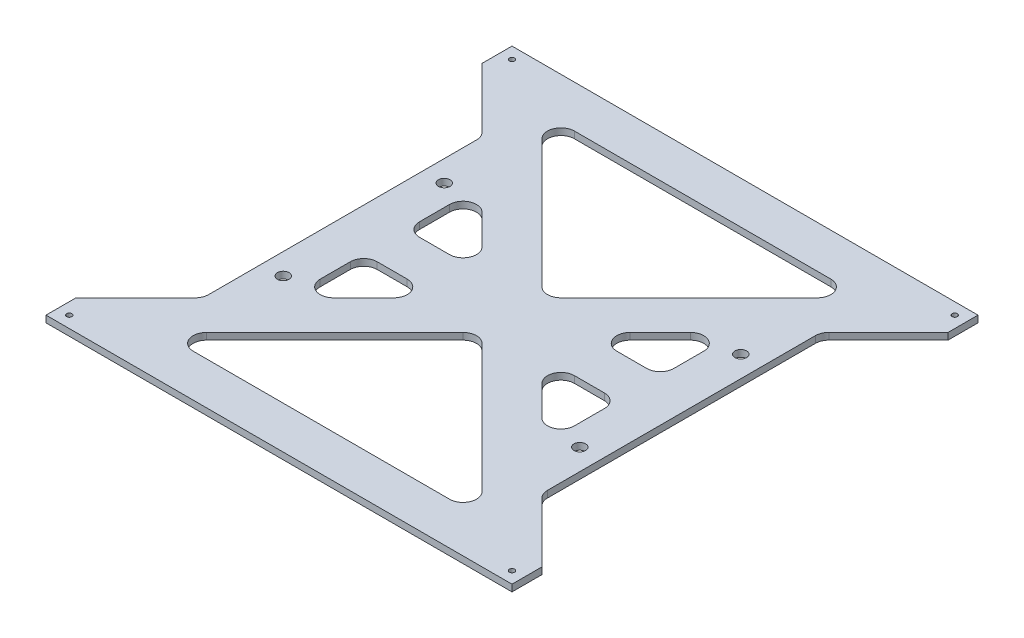
from build123d import *

# Parameters (mm, degrees)
SKETCH1_W             = 220
SKETCH1_H             = 220
BOSS_EXTRUDE1_DEPTH   = 3.175
M3X0_5_TAPPED_HOLE1_D = 2.5
SKETCH4_R             = 2.75
CUT_EXTRUDE1_DEPTH    = 4.175
CUT_EXTRUDE2_DEPTH    = 4.175


with BuildPart() as part:
    # Sketch1 → Boss-Extrude1 (new body)
    with BuildSketch(Plane(origin=(0, 0, 0), x_dir=(1, 0, 0), z_dir=(0, 1, 0))):
        Rectangle(SKETCH1_W, SKETCH1_H)
    extrude(amount=BOSS_EXTRUDE1_DEPTH)

    # M3x0.5 Tapped Hole1 (through all)
    with Locations(Plane(origin=(0, 3.175, 0), x_dir=(-1, 0, 0), z_dir=(0, 1, 0))):
        with Locations((104.5, -104.5), (-104.5, -104.5), (-104.5, 104.5), (104.5, 104.5)):
            Hole(M3X0_5_TAPPED_HOLE1_D / 2)

    # Sketch4 → Cut-Extrude1 (cut, through all)
    with BuildSketch(Plane(origin=(0, 3.175, 0), x_dir=(1, 0, 0), z_dir=(0, 1, 0))):
        with Locations(Location((-70, 38, 0), (0, 0, 270))):  # turned: the seam where the file's is
            Circle(SKETCH4_R)
        with Locations(Location((-70, -38, 0), (0, 0, 270))):  # turned: the seam where the file's is
            Circle(SKETCH4_R)
        with Locations(Location((70, -38, 0), (0, 0, 270))):  # turned: the seam where the file's is
            Circle(SKETCH4_R)
        with Locations(Location((70, 38, 0), (0, 0, 270))):  # turned: the seam where the file's is
            Circle(SKETCH4_R)
    extrude(amount=-CUT_EXTRUDE1_DEPTH, mode=Mode.SUBTRACT)

    # Sketch5 → Cut-Extrude2 (cut, through all)
    with BuildSketch(Plane(origin=(0, 3.175, 0), x_dir=(1, 0, 0), z_dir=(0, 1, 0))):
        with BuildLine():
            Line((-65.017736316, 79.159871939), (-4.490128061, 18.632263684))
            ThreePointArc((-4.490128061, 18.632263684), (0, 16.772391745), (4.490128061, 18.632263684))
            Line((4.490128061, 18.632263684), (65.017736316, 79.159871939))
            ThreePointArc((65.017736316, 79.159871939), (66.394243287, 86.080039796), (60.527608255, 90))
            Line((60.527608255, 90), (-60.527608255, 90))
            ThreePointArc((-60.527608255, 90), (-66.394243287, 86.080039796), (-65.017736316, 79.159871939))
        make_face()
        with BuildLine():
            Line((-4.490128061, -18.632263684), (-65.017736316, -79.159871939))
            ThreePointArc((-65.017736316, -79.159871939), (-66.394243287, -86.080039796), (-60.527608255, -90))
            Line((-60.527608255, -90), (60.527608255, -90))
            ThreePointArc((60.527608255, -90), (66.394243287, -86.080039796), (65.017736316, -79.159871939))
            Line((65.017736316, -79.159871939), (4.490128061, -18.632263684))
            ThreePointArc((4.490128061, -18.632263684), (0, -16.772391745), (-4.490128061, -18.632263684))
        make_face()
        with BuildLine():
            Line((-60, -16.35), (-60, -30.527608255))
            ThreePointArc((-60, -30.527608255), (-56.080039796, -36.394243287), (-49.159871939, -35.017736316))
            Line((-49.159871939, -35.017736316), (-34.982263684, -20.840128061))
            ThreePointArc((-34.982263684, -20.840128061), (-33.605756713, -13.919960204), (-39.472391745, -10))
            Line((-39.472391745, -10), (-53.65, -10))
            ThreePointArc((-53.65, -10), (-58.140128061, -11.859871939), (-60, -16.35))
        make_face()
        with BuildLine():
            Line((39.472391745, -10), (53.65, -10))
            ThreePointArc((53.65, -10), (58.140128061, -11.859871939), (60, -16.35))
            Line((60, -16.35), (60, -30.527608255))
            ThreePointArc((60, -30.527608255), (56.080039796, -36.394243287), (49.159871939, -35.017736316))
            Line((49.159871939, -35.017736316), (34.982263684, -20.840128061))
            ThreePointArc((34.982263684, -20.840128061), (33.605756713, -13.919960204), (39.472391745, -10))
        make_face()
        with BuildLine():
            Line((34.982263684, 20.840128061), (49.159871939, 35.017736316))
            ThreePointArc((49.159871939, 35.017736316), (56.080039796, 36.394243287), (60, 30.527608255))
            Line((60, 30.527608255), (60, 16.35))
            ThreePointArc((60, 16.35), (58.140128061, 11.859871939), (53.65, 10))
            Line((53.65, 10), (39.472391745, 10))
            ThreePointArc((39.472391745, 10), (33.605756713, 13.919960204), (34.982263684, 20.840128061))
        make_face()
        with BuildLine():
            Line((-39.472391745, 10), (-53.65, 10))
            ThreePointArc((-53.65, 10), (-58.140128061, 11.859871939), (-60, 16.35))
            Line((-60, 16.35), (-60, 30.527608255))
            ThreePointArc((-60, 30.527608255), (-56.080039796, 36.394243287), (-49.159871939, 35.017736316))
            Line((-49.159871939, 35.017736316), (-34.982263684, 20.840128061))
            ThreePointArc((-34.982263684, 20.840128061), (-33.605756713, 13.919960204), (-39.472391745, 10))
        make_face()
        with BuildLine():
            Line((-110, 95.857864376), (-110, -95.857864376))
            Line((-110, -95.857864376), (-81.859871939, -67.717736316))
            ThreePointArc((-81.859871939, -67.717736316), (-80.483364969, -65.657648051), (-80, -63.227608255))
            Line((-80, -63.227608255), (-80, 63.227608255))
            ThreePointArc((-80, 63.227608255), (-80.483364969, 65.657648051), (-81.859871939, 67.717736316))
            Line((-81.859871939, 67.717736316), (-110, 95.857864376))
        make_face()
        with BuildLine():
            Line((110, 95.857864376), (81.859871939, 67.717736316))
            ThreePointArc((81.859871939, 67.717736316), (80.483364969, 65.657648051), (80, 63.227608255))
            Line((80, 63.227608255), (80, -63.227608255))
            ThreePointArc((80, -63.227608255), (80.483364969, -65.657648051), (81.859871939, -67.717736316))
            Line((81.859871939, -67.717736316), (110, -95.857864376))
            Line((110, -95.857864376), (110, 95.857864376))
        make_face()
    extrude(amount=-CUT_EXTRUDE2_DEPTH, mode=Mode.SUBTRACT)


solid = part.part
